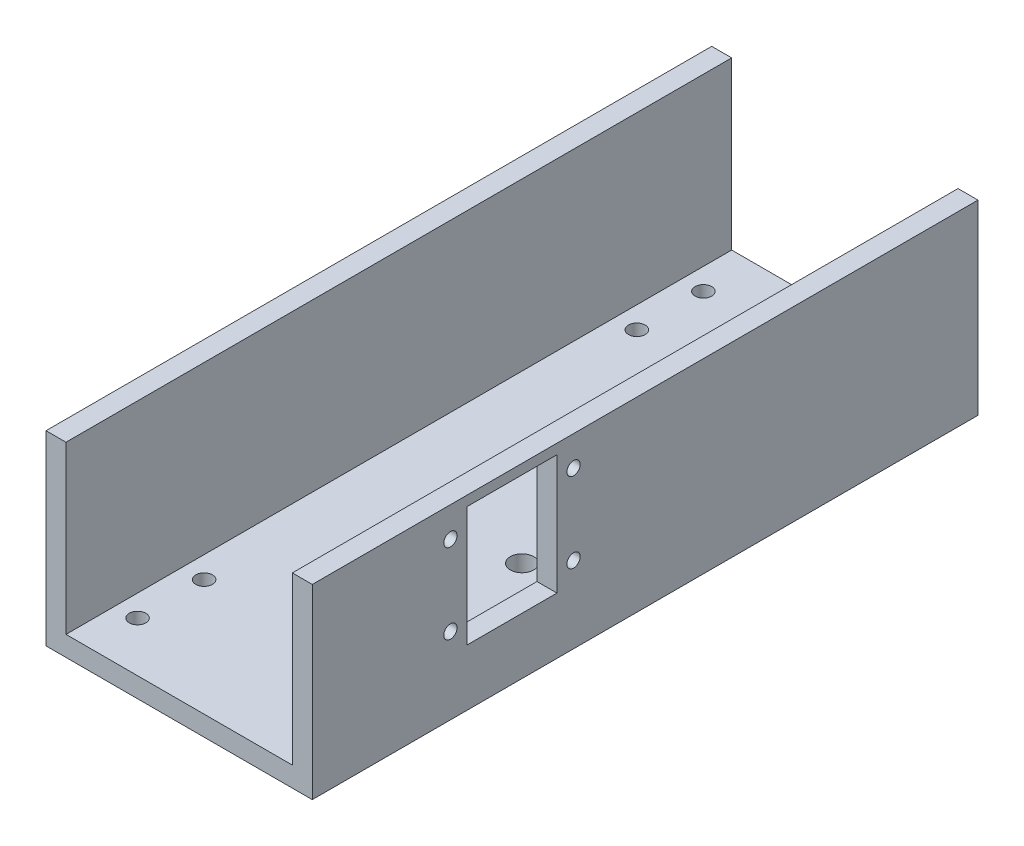
from build123d import *

# Parameters (mm, degrees)
EXTRUDE_1_DEPTH     = 200
CUT_EXTRUDE_2_REACH = 58
SKETCH_4_R          = 2.5
SKETCH_8_R          = 2
SKETCH_8_W          = 27
SKETCH_8_H          = 36
CUT_EXTRUDE_5_DEPTH = 10
SKETCH_9_R          = 3.5
CUT_EXTRUDE_6_DEPTH = 10
SKETCH_10_R         = 3.500000002
SKETCH_10_R_2       = 3.5
CUT_EXTRUDE_7_DEPTH = 10


with BuildPart() as part:
    # 草图1 → 凸台-拉伸1 (new body)
    with BuildSketch(Plane.XY):
        Polygon((-40, 0), (40, 0), (40, 56), (34, 56), (34, 6), (-34, 6), (-34, 56), (-40, 56), align=None)
    extrude(amount=EXTRUDE_1_DEPTH)

    # 草图4 → 切除-拉伸2 (cut, up to next)
    with BuildSketch(Plane.XZ, mode=Mode.PRIVATE) as cut_extrude_2_sk1:
        with Locations((-27.5, 185)):
            Circle(SKETCH_4_R)
    cut_extrude_2_tool1 = extrude(cut_extrude_2_sk1.sketch, amount=-CUT_EXTRUDE_2_REACH, mode=Mode.PRIVATE) & part.part
    add(cut_extrude_2_tool1.solids().sort_by_distance((-27.5, 0, 185))[0], mode=Mode.SUBTRACT)
    # 草图4 → 切除-拉伸2 (cut, up to next)
    with BuildSketch(Plane.XZ, mode=Mode.PRIVATE) as cut_extrude_2_sk2:
        with Locations((27.5, 185)):
            Circle(SKETCH_4_R)
    cut_extrude_2_tool2 = extrude(cut_extrude_2_sk2.sketch, amount=-CUT_EXTRUDE_2_REACH, mode=Mode.PRIVATE) & part.part
    add(cut_extrude_2_tool2.solids().sort_by_distance((27.5, 0, 185))[0], mode=Mode.SUBTRACT)
    # 草图4 → 切除-拉伸2 (cut, up to next)
    with BuildSketch(Plane.XZ, mode=Mode.PRIVATE) as cut_extrude_2_sk3:
        with Locations((-27.5, 165)):
            Circle(SKETCH_4_R)
    cut_extrude_2_tool3 = extrude(cut_extrude_2_sk3.sketch, amount=-CUT_EXTRUDE_2_REACH, mode=Mode.PRIVATE) & part.part
    add(cut_extrude_2_tool3.solids().sort_by_distance((-27.5, 0, 165))[0], mode=Mode.SUBTRACT)
    # 草图4 → 切除-拉伸2 (cut, up to next)
    with BuildSketch(Plane.XZ, mode=Mode.PRIVATE) as cut_extrude_2_sk4:
        with Locations((27.5, 35)):
            Circle(SKETCH_4_R)
    cut_extrude_2_tool4 = extrude(cut_extrude_2_sk4.sketch, amount=-CUT_EXTRUDE_2_REACH, mode=Mode.PRIVATE) & part.part
    add(cut_extrude_2_tool4.solids().sort_by_distance((27.5, 0, 35))[0], mode=Mode.SUBTRACT)
    # 草图4 → 切除-拉伸2 (cut, up to next)
    with BuildSketch(Plane.XZ, mode=Mode.PRIVATE) as cut_extrude_2_sk5:
        with Locations((-27.5, 35)):
            Circle(SKETCH_4_R)
    cut_extrude_2_tool5 = extrude(cut_extrude_2_sk5.sketch, amount=-CUT_EXTRUDE_2_REACH, mode=Mode.PRIVATE) & part.part
    add(cut_extrude_2_tool5.solids().sort_by_distance((-27.5, 0, 35))[0], mode=Mode.SUBTRACT)
    # 草图4 → 切除-拉伸2 (cut, up to next)
    with BuildSketch(Plane.XZ, mode=Mode.PRIVATE) as cut_extrude_2_sk6:
        with Locations((27.5, 15)):
            Circle(SKETCH_4_R)
    cut_extrude_2_tool6 = extrude(cut_extrude_2_sk6.sketch, amount=-CUT_EXTRUDE_2_REACH, mode=Mode.PRIVATE) & part.part
    add(cut_extrude_2_tool6.solids().sort_by_distance((27.5, 0, 15))[0], mode=Mode.SUBTRACT)
    # 草图4 → 切除-拉伸2 (cut, up to next)
    with BuildSketch(Plane.XZ, mode=Mode.PRIVATE) as cut_extrude_2_sk7:
        with Locations((-27.5, 15)):
            Circle(SKETCH_4_R)
    cut_extrude_2_tool7 = extrude(cut_extrude_2_sk7.sketch, amount=-CUT_EXTRUDE_2_REACH, mode=Mode.PRIVATE) & part.part
    add(cut_extrude_2_tool7.solids().sort_by_distance((-27.5, 0, 15))[0], mode=Mode.SUBTRACT)

    # 草图8 → 切除-拉伸5 (cut)
    with BuildSketch(Plane(origin=(40, 0, 0), x_dir=(0, 0, -1), z_dir=(1, 0, 0))):
        with Locations((-121.5, 23)):
            Circle(SKETCH_8_R)
        with Locations((-121.5, 47)):
            Circle(SKETCH_8_R)
        with Locations((-158.5, 47)):
            Circle(SKETCH_8_R)
        with Locations((-158.5, 23)):
            Circle(SKETCH_8_R)
        with Locations((-140, 35)):
            Rectangle(SKETCH_8_W, SKETCH_8_H)
    extrude(amount=-CUT_EXTRUDE_5_DEPTH, mode=Mode.SUBTRACT)

    # 草图9 → 切除-拉伸6 (cut)
    with BuildSketch(Plane(origin=(0, 6, 0), x_dir=(1, 0, 0), z_dir=(0, 1, 0))):
        with Locations((15.999999998, -166)):
            Circle(SKETCH_9_R)
    extrude(amount=-CUT_EXTRUDE_6_DEPTH, mode=Mode.SUBTRACT)

    # 草图10 → 切除-拉伸7 (cut)
    with BuildSketch(Plane(origin=(0, 6, 0), x_dir=(1, 0, 0), z_dir=(0, 1, 0))):
        with Locations((15.999999998, -113)):
            Circle(SKETCH_10_R)
        with Locations((15.999999998, -166)):
            Circle(SKETCH_10_R_2)
    extrude(amount=-CUT_EXTRUDE_7_DEPTH, mode=Mode.SUBTRACT)


solid = part.part
